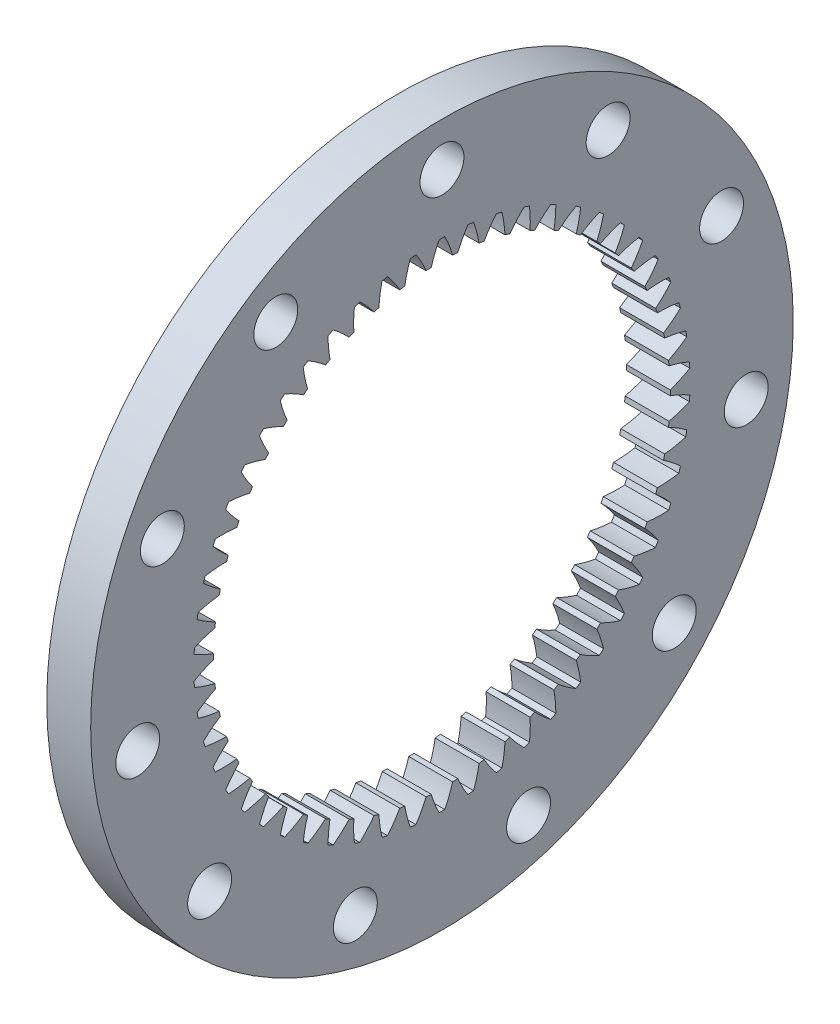
from build123d import *

# Parameters (mm, degrees)
BASPROSKE_W        = 5
BASPROSKE_H        = 14
TOOTHCUT_DEPTH     = 57.789083458
TEETHCUTS_COUNT    = 54
TEETHCUTS_ANGLE    = 353.333333333
SKETCH1_R          = 2.5
CUT_EXTRUDE1_DEPTH = 10


with BuildPart() as part:
    # BasProSke → Base-Revolve (revolve)
    with BuildSketch(Plane(origin=(0, 0, 0), x_dir=(1, 0, 0), z_dir=(0, 1, 0))):
        with Locations((2.5, 33)):
            Rectangle(BASPROSKE_W, BASPROSKE_H)
    revolve(axis=Axis((-10, 0, 0), (1, 0, 0)))

    # TooCutSke → ToothCut (cut, through all)
    with BuildSketch(Plane(origin=(0, 0, 0), x_dir=(0, 0, -1), z_dir=(1, 0, 0))):
        with BuildLine():
            ThreePointArc((1.227935627, 25.945558758), (0.829152918, 27.118086898), (0.324594082, 28.249135202))
            ThreePointArc((0.324594082, 28.249135202), (0, 28.251), (-0.324594082, 28.249135202))
            ThreePointArc((-0.324594082, 28.249135202), (-0.829152918, 27.118086898), (-1.227935627, 25.945558758))
            ThreePointArc((-1.227935627, 25.945558758), (0, 25.9746), (1.227935627, 25.945558758))
        make_face()
    toothcut = extrude(amount=TOOTHCUT_DEPTH, mode=Mode.SUBTRACT)

    # TeethCuts: ToothCut ×54 about axis
    teethcuts_axis = Axis((-10, 0, 0), (1, 0, 0))
    for i in range(1, TEETHCUTS_COUNT):
        add(toothcut.rotate(teethcuts_axis, i * TEETHCUTS_ANGLE / (TEETHCUTS_COUNT - 1)), mode=Mode.SUBTRACT)

    # Sketch1 → Cut-Extrude1 (cut)
    with BuildSketch(Plane(origin=(5, 0, 0), x_dir=(0, 0, -1), z_dir=(1, 0, 0))):
        with Locations((0, 35)):
            Circle(SKETCH1_R)
        with Locations((18.922428611, 29.443873649)):
            Circle(SKETCH1_R)
        with Locations((31.837119837, 14.539525455)):
            Circle(SKETCH1_R)
        with Locations((34.643750466, -4.98101934)):
            Circle(SKETCH1_R)
        with Locations((26.451235102, -22.920125688)):
            Circle(SKETCH1_R)
        with Locations((9.860639489, -33.582254077)):
            Circle(SKETCH1_R)
        with Locations((-9.860639489, -33.582254077)):
            Circle(SKETCH1_R)
        with Locations((-26.451235102, -22.920125688)):
            Circle(SKETCH1_R)
        with Locations((-34.643750466, -4.98101934)):
            Circle(SKETCH1_R)
        with Locations((-31.837119837, 14.539525455)):
            Circle(SKETCH1_R)
        with Locations((-18.922428611, 29.443873649)):
            Circle(SKETCH1_R)
    extrude(amount=-CUT_EXTRUDE1_DEPTH, mode=Mode.SUBTRACT)


solid = part.part
